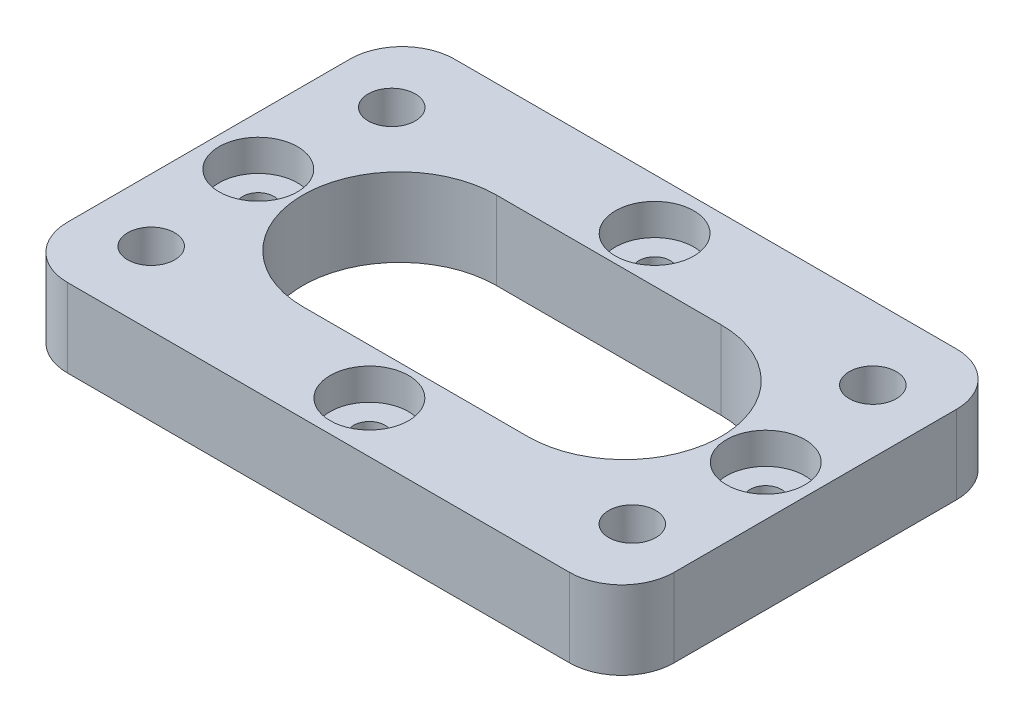
from build123d import *

# Parameters (mm, degrees)
SKETCH1_W           = 116
SKETCH1_H           = 74
BOSS_EXTRUDE1_DEPTH = 15
CUT_EXTRUDE1_DEPTH  = 15
SKETCH4_R           = 4.5
CUT_EXTRUDE2_DEPTH  = 15
SKETCH5_R           = 3
CUT_EXTRUDE3_DEPTH  = 15
SKETCH6_R           = 7.5
CUT_EXTRUDE4_DEPTH  = 6
CUT_EXTRUDE5_DEPTH  = 8
FILLET1_R           = 10
FILLET2_R           = 10


with BuildPart() as part:
    # Sketch1 → Boss-Extrude1 (new body)
    with BuildSketch(Plane(origin=(0, 0, 0), x_dir=(1, 0, 0), z_dir=(0, 1, 0))):
        with Locations((58, 37)):
            Rectangle(SKETCH1_W, SKETCH1_H)
    extrude(amount=BOSS_EXTRUDE1_DEPTH)

    # Sketch2 → Cut-Extrude1 (cut)
    with BuildSketch(Plane(origin=(0, 15, 0), x_dir=(1, 0, 0), z_dir=(0, 1, 0))):
        with BuildLine():
            Line((79.5, 55.5), (36.5, 55.5))
            ThreePointArc((36.5, 55.5), (23.418524548, 50.081475452), (18, 37))
            ThreePointArc((18, 37), (23.418524548, 23.918524548), (36.5, 18.5))
            Line((36.5, 18.5), (79.5, 18.5))
            ThreePointArc((79.5, 18.5), (92.581475452, 23.918524548), (98, 37))
            ThreePointArc((98, 37), (92.581475452, 50.081475452), (79.5, 55.5))
        make_face()
    extrude(amount=-CUT_EXTRUDE1_DEPTH, mode=Mode.SUBTRACT)

    # Sketch4 → Cut-Extrude2 (cut)
    with BuildSketch(Plane(origin=(0, 15, 0), x_dir=(1, 0, 0), z_dir=(0, 1, 0))):
        with Locations(Location((12, 60, 0), (0, 0, 270))):  # turned: the seam where the file's is
            Circle(SKETCH4_R)
        with Locations(Location((12, 14, 0), (0, 0, 270))):  # turned: the seam where the file's is
            Circle(SKETCH4_R)
        with Locations(Location((104, 60, 0), (0, 0, 270))):  # turned: the seam where the file's is
            Circle(SKETCH4_R)
        with Locations(Location((104, 14, 0), (0, 0, 270))):  # turned: the seam where the file's is
            Circle(SKETCH4_R)
    extrude(amount=-CUT_EXTRUDE2_DEPTH, mode=Mode.SUBTRACT)

    # Sketch5 → Cut-Extrude3 (cut)
    with BuildSketch(Plane(origin=(0, 15, 0), x_dir=(1, 0, 0), z_dir=(0, 1, 0))):
        with Locations(Location((9.48, 37, 0), (0, 0, 270))):  # turned: the seam where the file's is
            Circle(SKETCH5_R)
        with Locations(Location((58, 64.27, 0), (0, 0, 270))):  # turned: the seam where the file's is
            Circle(SKETCH5_R)
        with Locations(Location((106.52, 37, 0), (0, 0, 270))):  # turned: the seam where the file's is
            Circle(SKETCH5_R)
        with Locations(Location((58, 9.73, 0), (0, 0, 270))):  # turned: the seam where the file's is
            Circle(SKETCH5_R)
    extrude(amount=-CUT_EXTRUDE3_DEPTH, mode=Mode.SUBTRACT)

    # Sketch6 → Cut-Extrude4 (cut)
    with BuildSketch(Plane(origin=(0, 15, 0), x_dir=(1, 0, 0), z_dir=(0, 1, 0))):
        with Locations(Location((58, 64.27, 0), (0, 0, 270))):  # turned: the seam where the file's is
            Circle(SKETCH6_R)
        with Locations(Location((9.48, 37, 0), (0, 0, 270))):  # turned: the seam where the file's is
            Circle(SKETCH6_R)
        with Locations(Location((106.52, 37, 0), (0, 0, 270))):  # turned: the seam where the file's is
            Circle(SKETCH6_R)
        with Locations(Location((58, 9.73, 0), (0, 0, 270))):  # turned: the seam where the file's is
            Circle(SKETCH6_R)
    extrude(amount=-CUT_EXTRUDE4_DEPTH, mode=Mode.SUBTRACT)

    # Sketch8 → Cut-Extrude5 (cut)
    with BuildSketch(Plane(origin=(0, 0, 0), x_dir=(-1, 0, 0), z_dir=(0, -1, 0))):
        Polygon((-13.979937501, 21.38922735), (-19.38922735, 15.979937501), (-17.409289849, 8.590710151), (-10.020062499, 6.61077265), (-4.61077265, 12.020062499), (-6.590710151, 19.409289849), align=None)
        Polygon((-96.577343391, 15.850676148), (-101.891404254, 21.353547261), (-109.314060863, 19.502871113), (-111.422656609, 12.149323852), (-106.108595746, 6.646452739), (-98.685939137, 8.497128887), align=None)
        Polygon((-102.540331971, 52.490658978), (-96.766885895, 57.509439084), (-98.226553924, 65.018780105), (-105.459668029, 67.509341022), (-111.233114105, 62.490560916), (-109.773446076, 54.981219895), align=None)
        Polygon((-19.275478748, 57.636053655), (-13.590501786, 52.517277407), (-6.315023038, 54.881223752), (-4.724521252, 62.363946345), (-10.409498214, 67.482722593), (-17.684976962, 65.118776248), align=None)
    extrude(amount=-CUT_EXTRUDE5_DEPTH, mode=Mode.SUBTRACT)

    # Fillet1
    fillet1_edges = [part.edges().sort_by_distance(p)[0] for p in [
        (0, 7.5, 0),
        (116, 7.5, 0),
        (116, 7.5, -74),
    ]]
    fillet(fillet1_edges, radius=FILLET1_R)

    # Fillet2
    fillet2_edges = [part.edges().sort_by_distance(p)[0] for p in [
        (0, 7.5, -74),
    ]]
    fillet(fillet2_edges, radius=FILLET2_R)


solid = part.part
